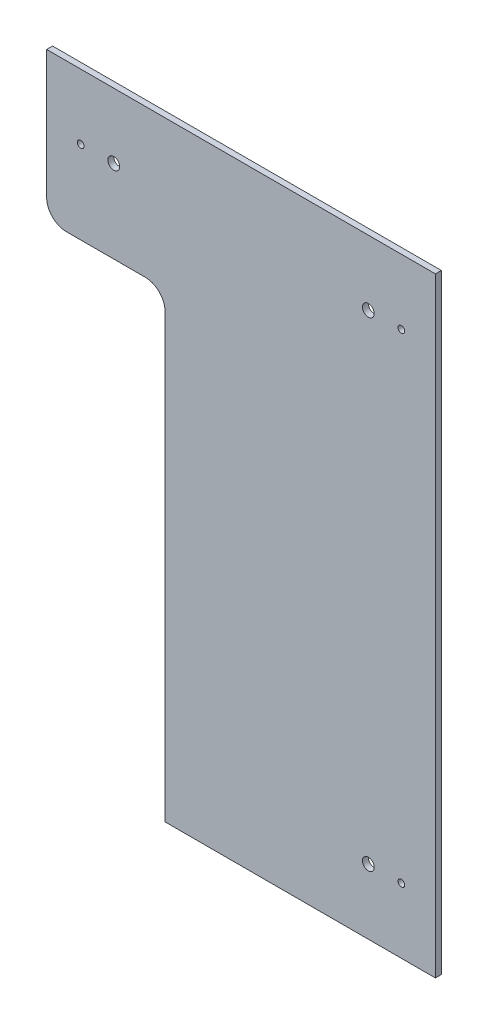
from build123d import *

# Parameters (mm, degrees)
ESQUISSE1_W             = 197
ESQUISSE1_H             = 309
ESQUISSE1_R             = 1.7
ESQUISSE1_R_2           = 3
BOSS_EXTRU_1_DEPTH      = 3
ESQUISSE2_W             = 60
ESQUISSE2_H             = 234
ENL_V_MAT_EXTRU_1_DEPTH = 4
CONG_1_R                = 10


with BuildPart() as part:
    # Esquisse1 → Boss.-Extru.1 (new body)
    with BuildSketch(Plane.XY):
        Rectangle(ESQUISSE1_W, ESQUISSE1_H)
        with Locations((81.25, 121.5)):
            Circle(ESQUISSE1_R, mode=Mode.SUBTRACT)
        with Locations((64.5, 121.5)):
            Circle(ESQUISSE1_R_2, mode=Mode.SUBTRACT)
        with Locations((81.25, -121.5)):
            Circle(ESQUISSE1_R, mode=Mode.SUBTRACT)
        with Locations((64.5, -121.5)):
            Circle(ESQUISSE1_R_2, mode=Mode.SUBTRACT)
        with Locations((-81.25, -121.5)):
            Circle(ESQUISSE1_R, mode=Mode.SUBTRACT)
        with Locations((-64.5, -121.5)):
            Circle(ESQUISSE1_R_2, mode=Mode.SUBTRACT)
        with Locations((-81.25, 121.5)):
            Circle(ESQUISSE1_R, mode=Mode.SUBTRACT)
        with Locations((-64.5, 121.5)):
            Circle(ESQUISSE1_R_2, mode=Mode.SUBTRACT)
    extrude(amount=BOSS_EXTRU_1_DEPTH)

    # Esquisse2 → Enlèv. mat.-Extru.1 (cut, through all)
    with BuildSketch(Plane.XY.offset(3)):
        with Locations((-68.5, -37.5)):
            Rectangle(ESQUISSE2_W, ESQUISSE2_H)
    extrude(amount=-ENL_V_MAT_EXTRU_1_DEPTH, mode=Mode.SUBTRACT)

    # Congé1
    cong_1_edges = [part.edges().sort_by_distance(p)[0] for p in [
        (-98.5, 79.5, 1.5),
        (-38.5, 79.5, 1.5),
    ]]
    fillet(cong_1_edges, radius=CONG_1_R)


solid = part.part
